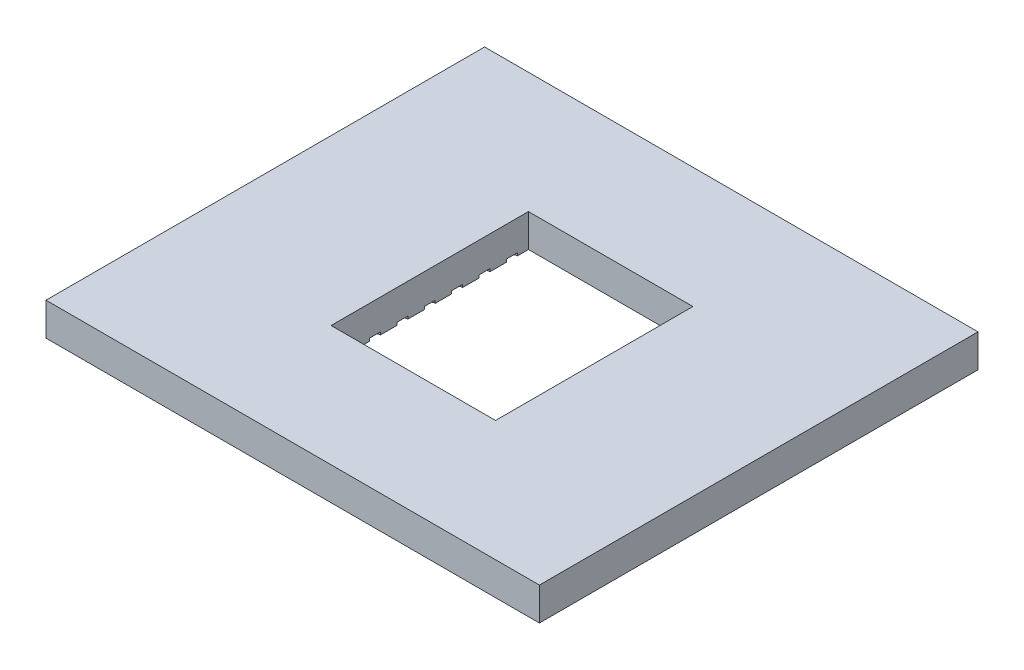
from build123d import *

# Parameters (mm, degrees)
SKETCH1_W               = 45
SKETCH1_H               = 40
BOSS_EXTRUDE1_DEPTH     = 3
SKETCH2_W               = 41
SKETCH2_H               = 36
SKETCH2_W_2             = 37
SKETCH2_H_2             = 32
CUT_EXTRUDE1_DEPTH      = 1
CUT_EXTRUDE2_REACH      = 32.253
SKETCH3_W               = 15
SKETCH3_H               = 18
CUT_EXTRUDE4_DEPTH      = 0.25
GLUE_SURFACE_COUNT      = 11
GLUE_SURFACE_PITCH      = 2.5
GLUE_SURFACE_COUNT_DIR2 = 11
GLUE_SURFACE_PITCH_DIR2 = 2.5


with BuildPart() as part:
    # Sketch1 → Boss-Extrude1 (new body)
    with BuildSketch(Plane(origin=(0, 0, 0), x_dir=(1, 0, 0), z_dir=(0, 1, 0))):
        Rectangle(SKETCH1_W, SKETCH1_H)
    extrude(amount=BOSS_EXTRUDE1_DEPTH)

    # Sketch2 → Cut-Extrude1 (cut)
    with BuildSketch(Plane.XZ):
        Rectangle(SKETCH2_W, SKETCH2_H)
        Rectangle(SKETCH2_W_2, SKETCH2_H_2, mode=Mode.SUBTRACT)
    extrude(amount=-CUT_EXTRUDE1_DEPTH, mode=Mode.SUBTRACT)

    # Sketch3 → Cut-Extrude2 (cut, up to next)
    with BuildSketch(Plane(origin=(0, 0, 0), x_dir=(-1, 0, 0), z_dir=(0, -1, 0)), mode=Mode.PRIVATE) as cut_extrude2_sk1:
        Rectangle(SKETCH3_W, SKETCH3_H)
    cut_extrude2_tool1 = extrude(cut_extrude2_sk1.sketch, amount=-CUT_EXTRUDE2_REACH, mode=Mode.PRIVATE) & part.part
    add(cut_extrude2_tool1.solids().sort_by_distance((0, 0, 0))[0], mode=Mode.SUBTRACT)

    # Sketch4 → Cut-Extrude4 (cut)
    with BuildSketch(Plane(origin=(0, 0, 0), x_dir=(-1, 0, 0), z_dir=(0, -1, 0))):
        with BuildLine():
            Line((12.5, -12), (12.5, -12.5))
            Line((12.5, -12.5), (12, -12.5))
            ThreePointArc((12, -12.5), (12.5, -13), (13, -12.5))
            ThreePointArc((13, -12.5), (12.853553391, -12.146446609), (12.5, -12))
        make_face()
        with BuildLine():
            Line((12, -12.5), (12.5, -12.5))
            Line((12.5, -12.5), (12.5, -12))
            ThreePointArc((12.5, -12), (12.146446609, -12.146446609), (12, -12.5))
        make_face()
    cut_extrude4 = extrude(amount=-CUT_EXTRUDE4_DEPTH, mode=Mode.SUBTRACT)

    # Glue Surface: Cut-Extrude4 11 × 11
    with Locations(*[(i * GLUE_SURFACE_PITCH, 0, -j * GLUE_SURFACE_PITCH_DIR2) for i in range(GLUE_SURFACE_COUNT) for j in range(GLUE_SURFACE_COUNT_DIR2) if (i, j) != (0, 0)]):
        add(cut_extrude4, mode=Mode.SUBTRACT)


solid = part.part
